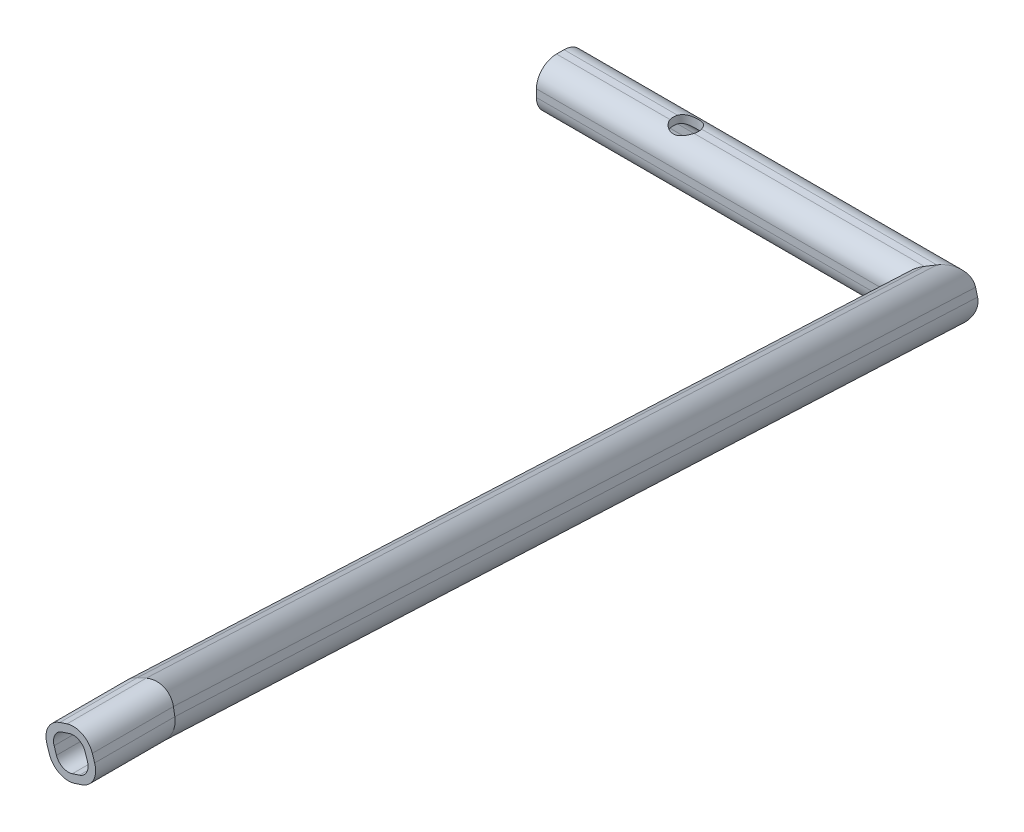
from build123d import *

# Parameters (mm, degrees)
SKETCH21_R              = 5
CUT_EXTRUDE3_DEPTH      = 210.892061542
CUT_EXTRUDE3_DEPTH_BACK = 10.5


with BuildPart() as part:
    # Sweep-Thin3: sweep along a curve in space
    with BuildLine() as sweep_thin3_path:
        Line((0, 0, 0), (150, 0, 0))
        Line((150, 0, 0), (335.07515147, 200, 500))
        Line((335.07515147, 200, 500), (335.07515147, 200, 530))
    # Sketch2 → Sweep-Thin3 (sweep)
    with BuildSketch(Plane(origin=(0, 0, 0), x_dir=(0, 0, -1), z_dir=(1, 0, 0))):
        with BuildLine():
            Line((1.5, 9.5), (-1.5, 9.5))
            ThreePointArc((-1.5, 9.5), (-7.156854249, 7.156854249), (-9.5, 1.5))
            Line((-9.5, 1.5), (-9.5, -1.5))
            ThreePointArc((-9.5, -1.5), (-7.156854249, -7.156854249), (-1.5, -9.5))
            Line((-1.5, -9.5), (1.5, -9.5))
            ThreePointArc((1.5, -9.5), (7.156854249, -7.156854249), (9.5, -1.5))
            Line((9.5, -1.5), (9.5, 1.5))
            ThreePointArc((9.5, 1.5), (7.156854249, 7.156854249), (1.5, 9.5))
        make_face()
        with BuildLine():
            Line((1.5, 6.5), (-1.5, 6.5))
            ThreePointArc((-1.5, 6.5), (-5.035533906, 5.035533906), (-6.5, 1.5))
            Line((-6.5, 1.5), (-6.5, -1.5))
            ThreePointArc((-6.5, -1.5), (-5.035533906, -5.035533906), (-1.5, -6.5))
            Line((-1.5, -6.5), (1.5, -6.5))
            ThreePointArc((1.5, -6.5), (5.035533906, -5.035533906), (6.5, -1.5))
            Line((6.5, -1.5), (6.5, 1.5))
            ThreePointArc((6.5, 1.5), (5.035533906, 5.035533906), (1.5, 6.5))
        make_face(mode=Mode.SUBTRACT)
    sweep(path=sweep_thin3_path.line, transition=Transition.RIGHT)

    # Sketch21 → Cut-Extrude3 (cut, two sides)
    with BuildSketch(Plane(origin=(0, 0, 0), x_dir=(1, 0, 0), z_dir=(0, 1, 0))) as cut_extrude3_sk:
        with Locations((50, 0)):
            Circle(SKETCH21_R)
    extrude(amount=CUT_EXTRUDE3_DEPTH, mode=Mode.SUBTRACT)
    extrude(cut_extrude3_sk.sketch, amount=-CUT_EXTRUDE3_DEPTH_BACK, mode=Mode.SUBTRACT)


solid = part.part
